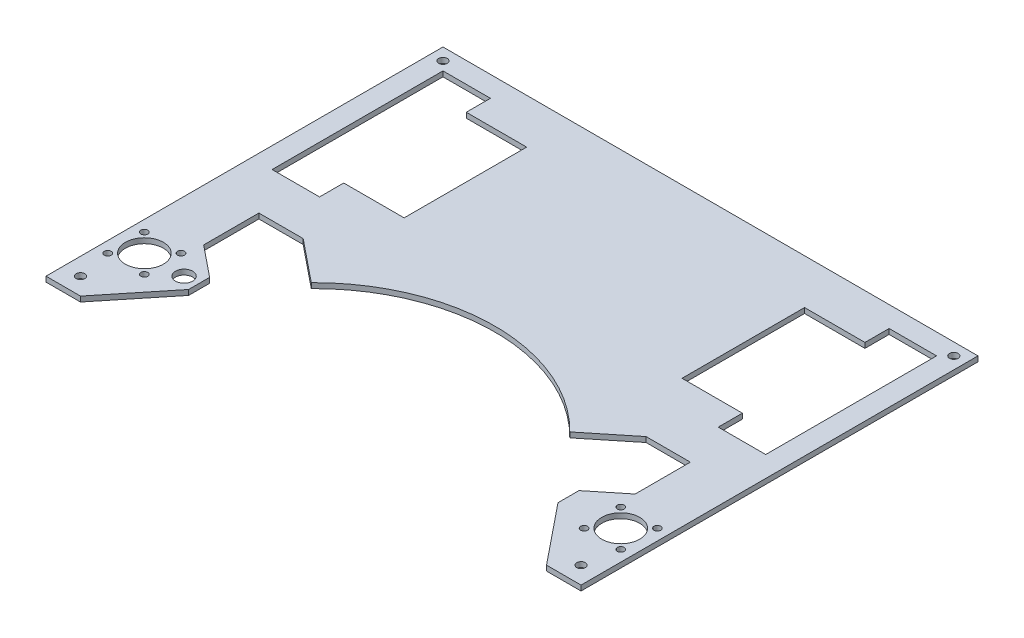
from build123d import *

# Parameters (mm, degrees)
ESQUISSE1_R      = 2.5
ESQUISSE1_R_2    = 11
ESQUISSE1_R_3    = 2
ESQUISSE1_R_4    = 5
EXTRUSION1_DEPTH = 3


with BuildPart() as part:
    # Esquisse1 → Extrusion1 (new body)
    with BuildSketch(Plane(origin=(0, 0, 0), x_dir=(1, 0, 0), z_dir=(0, 1, 0))):
        with BuildLine():
            Line((155, 0), (-155, 0))
            Line((-155, 0), (-155, -230))
            Line((-155, -230), (-135, -230))
            Line((-135, -230), (-107, -195.351767722))
            Line((-107, -195.351767722), (-107, -183.195768703))
            Line((-107, -183.195768703), (-125, -168.649572061))
            Line((-125, -168.649572061), (-125, -136.649572061))
            Line((-125, -136.649572061), (-99.334512084, -136.649572061))
            Line((-99.334512084, -136.649572061), (-74.890281348, -156.403493564))
            ThreePointArc((-74.890281348, -156.403493564), (0, -125), (74.890281348, -156.403493564))
            Line((74.890281348, -156.403493564), (99.334512084, -136.649572061))
            Line((99.334512084, -136.649572061), (125, -136.649572061))
            Line((125, -136.649572061), (125, -168.649572061))
            Line((125, -168.649572061), (107, -183.195768703))
            Line((107, -183.195768703), (107, -195.351767722))
            Line((107, -195.351767722), (135, -230))
            Line((135, -230), (155, -230))
            Line((155, -230), (155, 0))
        make_face()
        with Locations((-148, -7)):
            Circle(ESQUISSE1_R, mode=Mode.SUBTRACT)
        with Locations((148, -7)):
            Circle(ESQUISSE1_R, mode=Mode.SUBTRACT)
        with Locations((-145, -220)):
            Circle(ESQUISSE1_R, mode=Mode.SUBTRACT)
        with Locations((145, -220)):
            Circle(ESQUISSE1_R, mode=Mode.SUBTRACT)
        with Locations((-138, -190)):
            Circle(ESQUISSE1_R_2, mode=Mode.SUBTRACT)
        with Locations((-148.606601718, -179.393398282)):
            Circle(ESQUISSE1_R_3, mode=Mode.SUBTRACT)
        with Locations((-127.393398282, -179.393398282)):
            Circle(ESQUISSE1_R_3, mode=Mode.SUBTRACT)
        with Locations((-127.393398282, -200.606601718)):
            Circle(ESQUISSE1_R_3, mode=Mode.SUBTRACT)
        with Locations((-148.606601718, -200.606601718)):
            Circle(ESQUISSE1_R_3, mode=Mode.SUBTRACT)
        with Locations((138, -190)):
            Circle(ESQUISSE1_R_2, mode=Mode.SUBTRACT)
        with Locations((148.606601718, -200.606601718)):
            Circle(ESQUISSE1_R_3, mode=Mode.SUBTRACT)
        with Locations((127.393398282, -200.606601718)):
            Circle(ESQUISSE1_R_3, mode=Mode.SUBTRACT)
        with Locations((127.393398282, -179.393398282)):
            Circle(ESQUISSE1_R_3, mode=Mode.SUBTRACT)
        with Locations((148.606601718, -179.393398282)):
            Circle(ESQUISSE1_R_3, mode=Mode.SUBTRACT)
        with Locations((-115, -190)):
            Circle(ESQUISSE1_R_4, mode=Mode.SUBTRACT)
        Polygon((-80.5, -26), (-115.5, -26), (-115.5, -12), (-143, -12), (-143, -111), (-115.5, -111), (-115.5, -97), (-80.5, -97), align=None, mode=Mode.SUBTRACT)
        Polygon((115.5, -26), (115.5, -12), (143, -12), (143, -111), (115.5, -111), (115.5, -97), (80.5, -97), (80.5, -26), align=None, mode=Mode.SUBTRACT)
    extrude(amount=EXTRUSION1_DEPTH)


solid = part.part
